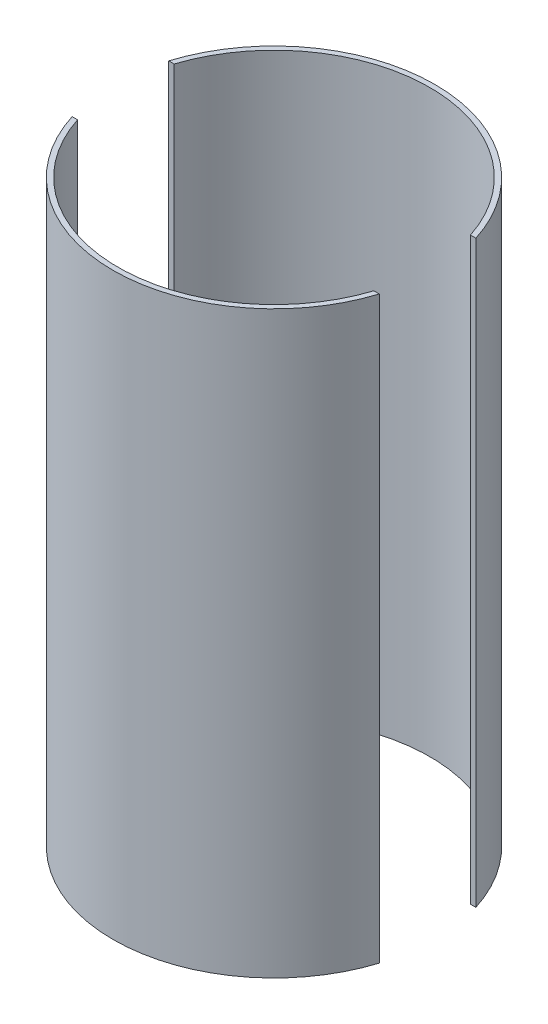
from build123d import *

# Parameters (mm, degrees)
SKETCH4_R               = 63.5
SKETCH4_R_2             = 61.468
BOSS_EXTRUDE1_DEPTH     = 114.3
CUT_EXTRUDE2_DEPTH      = 115.3
CUT_EXTRUDE2_DEPTH_BACK = 115.3


with BuildPart() as part:
    # Sketch4 → Boss-Extrude1 (new body, symmetric)
    with BuildSketch(Plane(origin=(0, 0, 0), x_dir=(1, 0, 0), z_dir=(0, 1, 0))):
        Circle(SKETCH4_R)
        Circle(SKETCH4_R_2, mode=Mode.SUBTRACT)
    extrude(amount=BOSS_EXTRUDE1_DEPTH, both=True)

    # Sketch5 → Cut-Extrude2 (cut, two sides)
    with BuildSketch(Plane(origin=(0, 0, 0), x_dir=(1, 0, 0), z_dir=(0, 1, 0))) as cut_extrude2_sk:
        Polygon((76.2, 19.05), (-76.2, 19.05), (-76.2, 18.415), (-76.2, -18.415), (-76.2, -19.05), (76.2, -19.05), (76.2, -18.415), (76.2, 18.415), align=None)
    extrude(amount=CUT_EXTRUDE2_DEPTH, mode=Mode.SUBTRACT)
    extrude(cut_extrude2_sk.sketch, amount=-CUT_EXTRUDE2_DEPTH_BACK, mode=Mode.SUBTRACT)


solid = part.part
